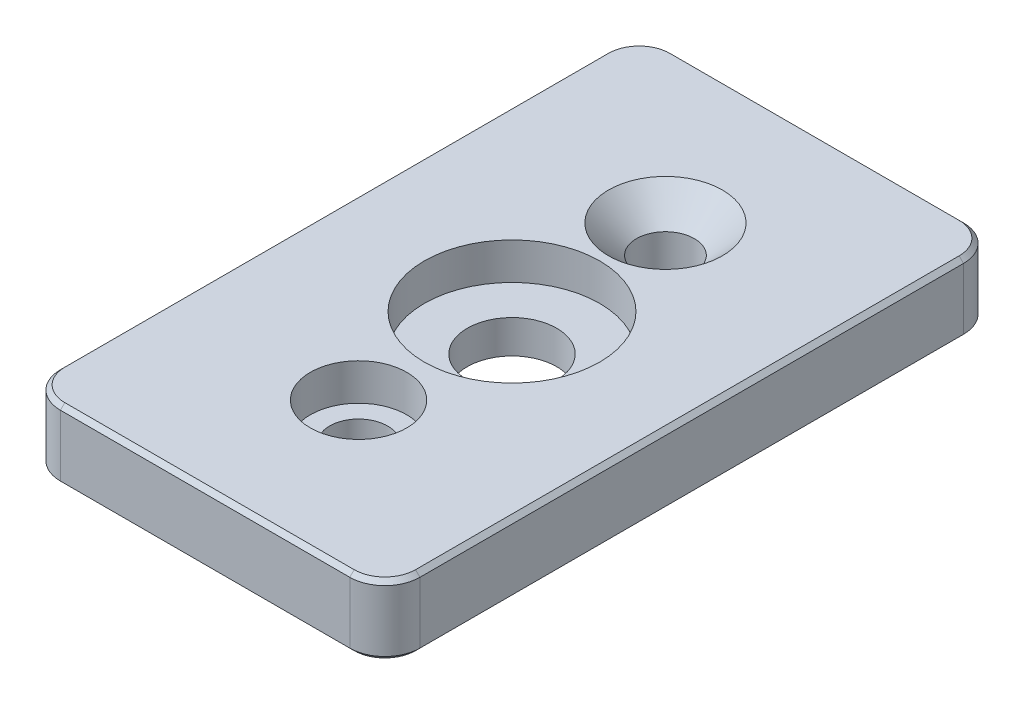
from build123d import *

# Parameters (mm, degrees)
SKETCH1_W           = 41
SKETCH1_H           = 70
SKETCH1_R           = 3.3
BOSS_EXTRUDE1_DEPTH = 8
SKETCH2_R           = 5.5
CUT_EXTRUDE1_DEPTH  = 4.2
CHAMFER2_SIZE       = 3.2
FILLET1_R           = 4
CHAMFER4_SIZE       = 0.5
SKETCH4_R           = 5.1
CUT_EXTRUDE3_DEPTH  = 9
SKETCH5_R           = 10
CUT_EXTRUDE4_DEPTH  = 4.2


with BuildPart() as part:
    # Sketch1 → Boss-Extrude1 (new body)
    with BuildSketch(Plane(origin=(0, 0, 0), x_dir=(1, 0, 0), z_dir=(0, 1, 0))):
        Rectangle(SKETCH1_W, SKETCH1_H)
        with Locations((0, 17.5)):
            Circle(SKETCH1_R, mode=Mode.SUBTRACT)
        with Locations((0, -17.5)):
            Circle(SKETCH1_R, mode=Mode.SUBTRACT)
    extrude(amount=BOSS_EXTRUDE1_DEPTH)

    # Sketch2 → Cut-Extrude1 (cut)
    with BuildSketch(Plane(origin=(0, 8, 0), x_dir=(1, 0, 0), z_dir=(0, 1, 0))):
        with Locations((0, -17.5)):
            Circle(SKETCH2_R)
    extrude(amount=-CUT_EXTRUDE1_DEPTH, mode=Mode.SUBTRACT)

    # Chamfer2
    chamfer2_edges = [part.edges().sort_by_distance(p)[0] for p in [
        (-3.3, 8, -17.5),
    ]]
    chamfer(chamfer2_edges, length=CHAMFER2_SIZE)

    # Fillet1
    fillet1_edges = [part.edges().sort_by_distance(p)[0] for p in [
        (20.5, 4, 35),
        (-20.5, 4, 35),
        (-20.5, 4, -35),
        (20.5, 4, -35),
    ]]
    fillet(fillet1_edges, radius=FILLET1_R)

    # Chamfer4
    chamfer4_edges = [part.edges().sort_by_distance(p)[0] for p in [
        (0, 0, 35),
        (0, 8, 35),
        (20.5, 0, 0),
        (-20.5, 0, 0),
        (0, 0, -35),
        (-19.328427125, 0, -33.828427125),
        (19.328427125, 0, -33.828427125),
        (19.328427125, 0, 33.828427125),
        (-19.328427125, 0, 33.828427125),
        (-20.5, 8, 0),
        (20.5, 8, 0),
        (0, 8, -35),
        (-19.328427125, 8, -33.828427125),
        (19.328427125, 8, -33.828427125),
        (19.328427125, 8, 33.828427125),
        (-19.328427125, 8, 33.828427125),
    ]]
    chamfer(chamfer4_edges, length=CHAMFER4_SIZE)

    # Sketch4 → Cut-Extrude3 (cut, through all)
    with BuildSketch(Plane(origin=(0, 8, 0), x_dir=(1, 0, 0), z_dir=(0, 1, 0))):
        Circle(SKETCH4_R)
    extrude(amount=-CUT_EXTRUDE3_DEPTH, mode=Mode.SUBTRACT)

    # Sketch5 → Cut-Extrude4 (cut)
    with BuildSketch(Plane(origin=(0, 8, 0), x_dir=(1, 0, 0), z_dir=(0, 1, 0))):
        Circle(SKETCH5_R)
    extrude(amount=-CUT_EXTRUDE4_DEPTH, mode=Mode.SUBTRACT)


solid = part.part
